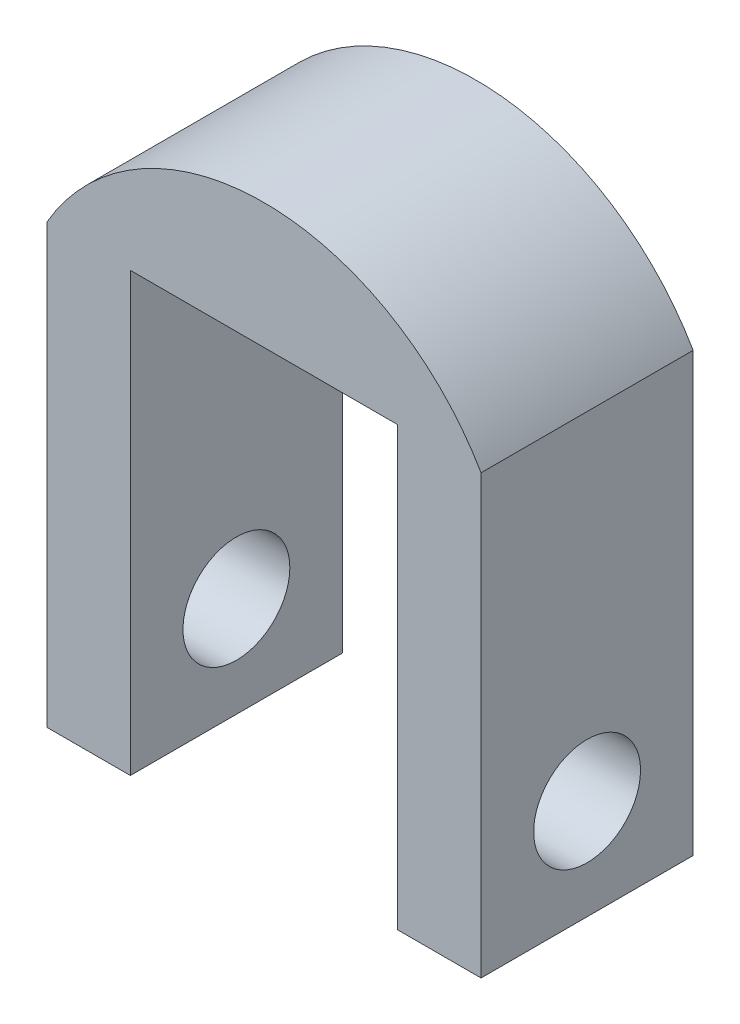
from build123d import *

# Parameters (mm, degrees)
BOSS_EXTRUDE1_DEPTH = 12.7
SKETCH2_R           = 3.2
CUT_EXTRUDE1_DEPTH  = 27


with BuildPart() as part:
    # Sketch1 → Boss-Extrude1 (new body)
    with BuildSketch(Plane.XY):
        with BuildLine():
            Line((0, 0), (0, 26.2))
            ThreePointArc((0, 26.2), (-13, 33.716685226), (-26, 26.2))
            Line((-26, 26.2), (-26, 0))
            Line((-26, 0), (-21, 0))
            Line((-21, 0), (-21, 26.2))
            Line((-21, 26.2), (-5, 26.2))
            Line((-5, 26.2), (-5, 0))
            Line((-5, 0), (0, 0))
        make_face()
    extrude(amount=BOSS_EXTRUDE1_DEPTH)

    # Sketch2 → Cut-Extrude1 (cut, through all)
    with BuildSketch(Plane(origin=(0, 0, 0), x_dir=(0, 0, -1), z_dir=(1, 0, 0))):
        with Locations((-6.35, 6)):
            Circle(SKETCH2_R)
    extrude(amount=-CUT_EXTRUDE1_DEPTH, mode=Mode.SUBTRACT)


solid = part.part
